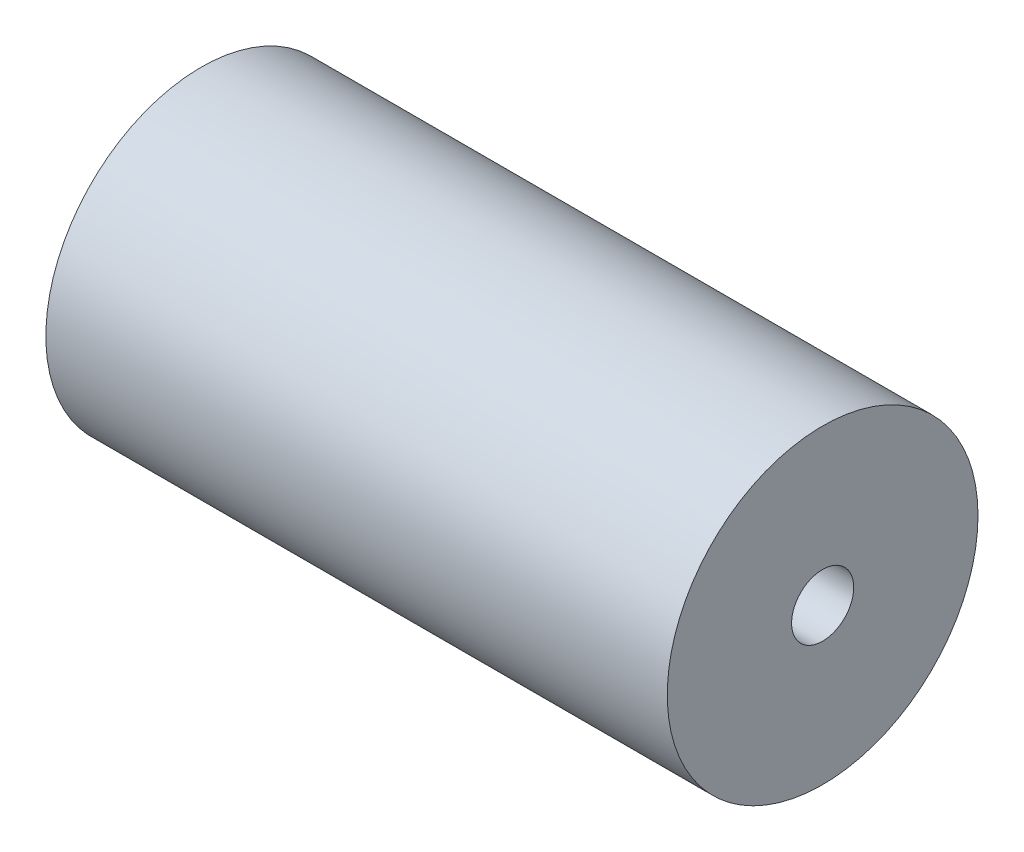
from build123d import *

# Parameters (mm, degrees)
SKETCH1_R           = 2.5
SKETCH1_R_2         = 0.5
BOSS_EXTRUDE1_DEPTH = 10


with BuildPart() as part:
    # Sketch1 → Boss-Extrude1 (new body)
    with BuildSketch(Plane(origin=(0, 0, 0), x_dir=(0, 0, -1), z_dir=(1, 0, 0))):
        Circle(SKETCH1_R)
        Circle(SKETCH1_R_2, mode=Mode.SUBTRACT)
    extrude(amount=BOSS_EXTRUDE1_DEPTH)


solid = part.part
